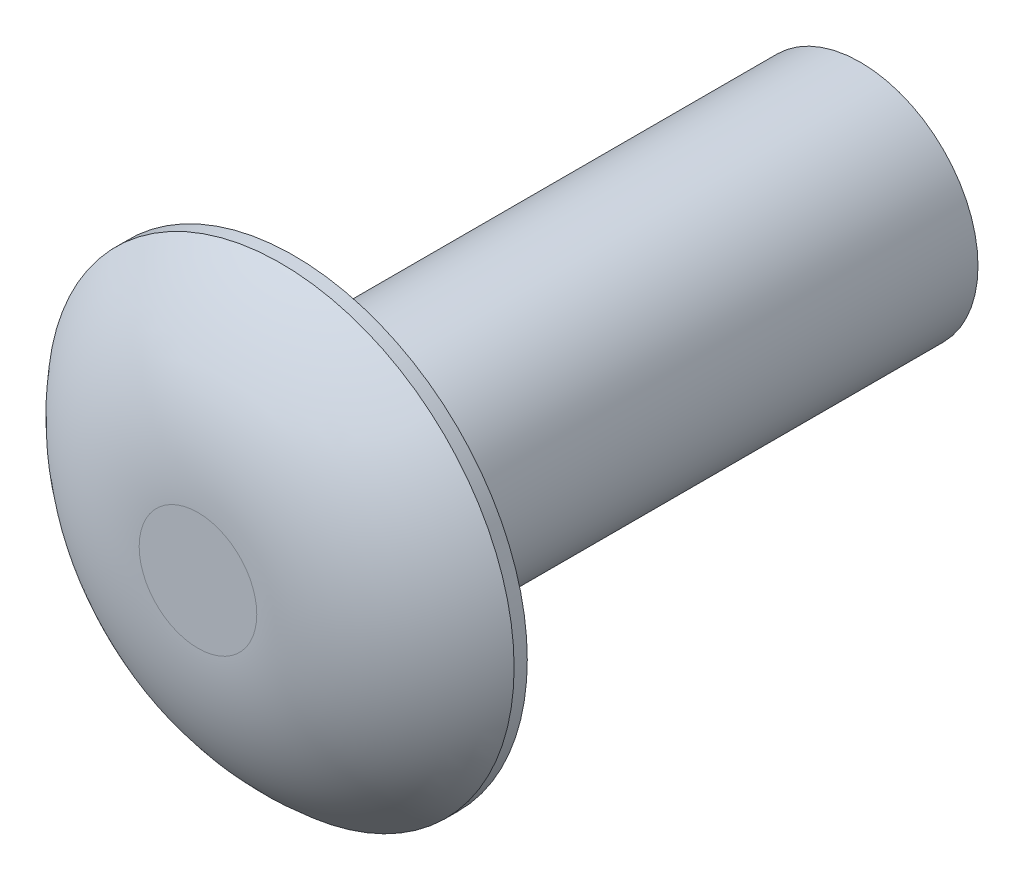
from build123d import *

# Parameters (mm, degrees)
CUT_EXTRUDE1_DEPTH      = 4.1496001
CUT_EXTRUDE1_DEPTH_BACK = 4.1496001
CUT_EXTRUDE2_DEPTH      = 4.1496001
CUT_EXTRUDE2_DEPTH_BACK = 4.1496001
FILLET2_R               = 0.254
SKETCH7_W               = 1.840958013
SKETCH7_H               = 16.135739168
CUT_EXTRUDE3_DEPTH      = 4.1496001
CUT_EXTRUDE3_DEPTH_BACK = 4.1496001


with BuildPart() as part:
    # Sketch2 → Revolve1 (revolve)
    with BuildSketch(Plane(origin=(0, 0, 0), x_dir=(0, 0, -1), z_dir=(1, 0, 0))):
        with BuildLine():
            Line((-16.5862, 0), (-16.5862, 0.79375))
            Line((-16.5862, 0.79375), (-1.2954, 0.79375))
            ThreePointArc((-1.2954, 0.79375), (-1.001833933, 2.097500262), (-0.1778, 3.1496))
            Line((-0.1778, 3.1496), (0, 3.1496))
            Line((0, 3.1496), (0, 1.5875))
            Line((0, 1.5875), (7.6454, 1.5875))
            Line((7.6454, 1.5875), (7.6454, 1.496709354))
            Line((7.6454, 1.496709354), (7.6454, 0))
            Line((7.6454, 0), (-16.5862, 0))
        make_face()
    revolve(axis=Axis((0, 0, 16.5862), (0, 0, -1)))

    # Sketch3 → Cut-Extrude1 (cut, two sides)
    with BuildSketch(Plane(origin=(0, 0, 0), x_dir=(1, 0, 0), z_dir=(0, 1, 0))) as cut_extrude1_sk:
        Polygon((0, -16.5862), (0.99695, -15.286949465), (0.99695, -17.0942), (-0.99695, -17.0942), (-0.99695, -15.286949465), align=None)
    extrude(amount=CUT_EXTRUDE1_DEPTH, mode=Mode.SUBTRACT)
    extrude(cut_extrude1_sk.sketch, amount=-CUT_EXTRUDE1_DEPTH_BACK, mode=Mode.SUBTRACT)

    # Sketch5 → Cut-Extrude2 (cut, two sides)
    with BuildSketch(Plane(origin=(0, 0, 0), x_dir=(0, 0, -1), z_dir=(1, 0, 0))) as cut_extrude2_sk:
        Polygon((-16.5862, 0), (-15.55176486, 1.11125), (-16.9037, 1.11125), (-16.9037, -1.11125), (-15.55176486, -1.11125), align=None)
    extrude(amount=CUT_EXTRUDE2_DEPTH, mode=Mode.SUBTRACT)
    extrude(cut_extrude2_sk.sketch, amount=-CUT_EXTRUDE2_DEPTH_BACK, mode=Mode.SUBTRACT)

    # Fillet2
    fillet2_edges = [part.edges().sort_by_distance(p)[0] for p in [
        (0, -1.5875, 0),
    ]]
    fillet(fillet2_edges, radius=FILLET2_R)

    # Sketch7 → Cut-Extrude3 (cut, two sides)
    with BuildSketch(Plane(origin=(0, 0, 0), x_dir=(1, 0, 0), z_dir=(0, 1, 0))) as cut_extrude3_sk:
        with Locations((0.126729007, -9.363269584)):
            Rectangle(SKETCH7_W, SKETCH7_H)
    extrude(amount=CUT_EXTRUDE3_DEPTH, mode=Mode.SUBTRACT)
    extrude(cut_extrude3_sk.sketch, amount=-CUT_EXTRUDE3_DEPTH_BACK, mode=Mode.SUBTRACT)


solid = part.part
